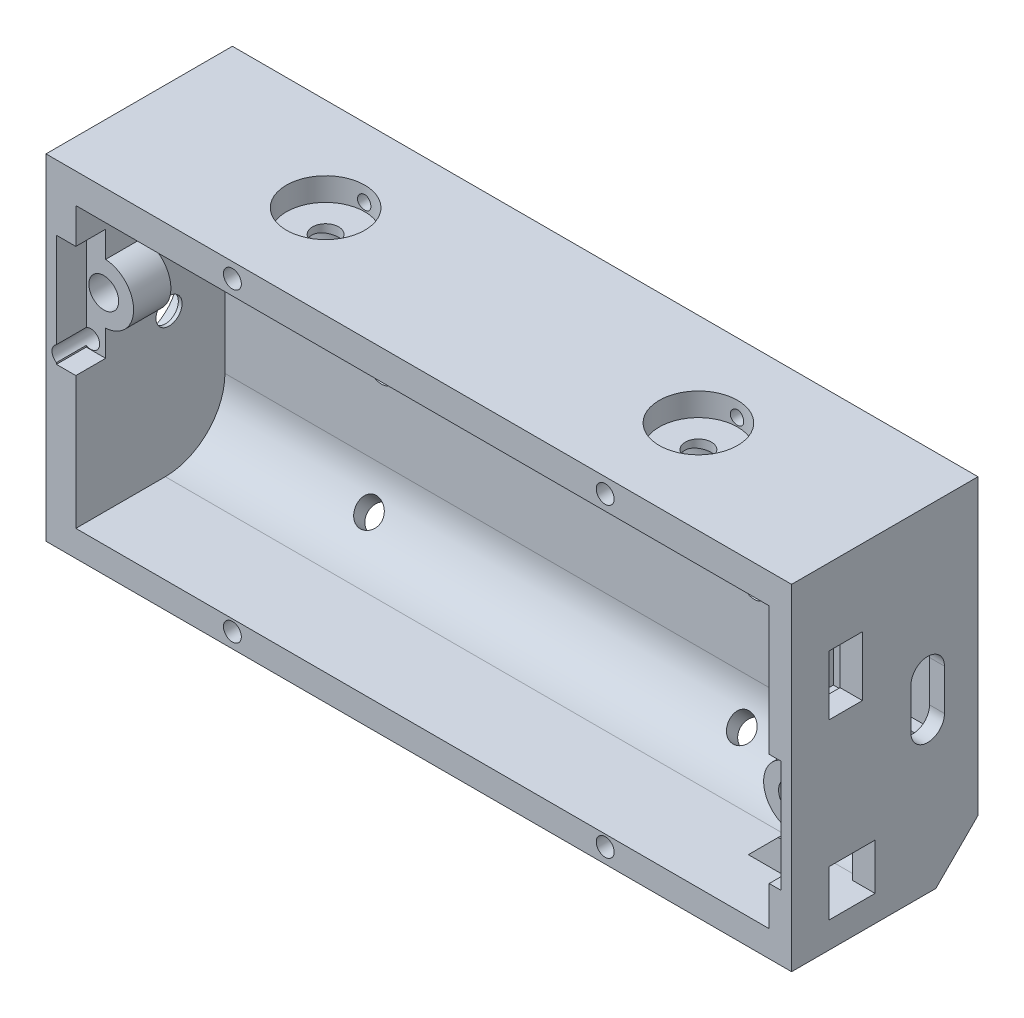
from build123d import *
from build123d.topology import SkipClean

# Parameters (mm, degrees)
ESBO_O1_W                   = 100
ESBO_O1_H                   = 45
ESBO_O1_W_2                 = 93
ESBO_O1_H_2                 = 37.5
RESSALTO_EXTRUS_O1_DEPTH    = 25
ESBO_O1_3_W                 = 93
ESBO_O1_3_H                 = 37.5
RESSALTO_EXTRUS_O2_DEPTH    = 5
ESBO_O2_R                   = 5.25
ESBO_O2_R_2                 = 1.75
CORTE_EXTRUS_O1_DEPTH       = 3.1
ESBO_O14_R                  = 5.25
ESBO_O14_R_2                = 1.75
CORTE_EXTRUS_O17_DEPTH      = 3.5
ESBO_O4_R                   = 5.15
ESBO_O4_R_2                 = 1.75
CORTE_EXTRUS_O2_DEPTH       = 3.5
CORTE_EXTRUS_O3_DEPTH       = 106.50473923
FILETE1_R                   = 8
ESBO_O6_W                   = 12.5
ESBO_O6_H                   = 6.5
ESBO_O6_R                   = 1.75
CORTE_EXTRUS_O4_DEPTH       = 3.2
ESBO_O4_2_R                 = 1.75
CORTE_EXTRUS_O5_DEPTH       = 61.259853966
CORTE_EXTRUS_O6_REACH       = 73.764
ESBO_O2_2_R                 = 1.75
ESBO_O6_2_R                 = 1.75
CORTE_EXTRUS_O8_DEPTH       = 78.347822255
DIY_CHARGER_START           = -20
ESBO_O8_W                   = 16
ESBO_O8_H                   = 16
DIY_CHARGER_DEPTH           = 6
DIY_CHARGER_DEPTH_BACK      = 1.5
CORTE_EXTRUS_O11_DEPTH      = 104.611051534
ESBO_O10_R                  = 1
CORTE_EXTRUS_O12_DEPTH      = 2
CORTE_EXTRUS_O12_DEPTH_BACK = 1.6
ESBO_O12_W                  = 6.2
ESBO_O12_H                  = 6.2
ESBO_O12_W_2                = 4.5
ESBO_O12_H_2                = 8
CORTE_EXTRUS_O14_DEPTH      = 103.665719693
ESBO_O12_3_R                = 1
CORTE_EXTRUS_O15_DEPTH      = 3
CORTE_EXTRUS_O15_DEPTH_BACK = 1.5
RESSALTO_EXTRUS_O4_START    = -4
RESSALTO_EXTRUS_O4_DEPTH    = 5
ESBO_O13_3_R                = 2
CORTE_EXTRUS_O16_DEPTH      = 10
CORTE_EXTRUS_O18_REACH      = 107.505
ESBO_O14_2_R                = 1.75
ESBO_O16_W                  = 4.7
ESBO_O16_H                  = 15
CORTE_EXTRUS_O19_DEPTH      = 4
ESBO_O17_R                  = 1.2
CORTE_EXTRUS_O20_DEPTH      = 6
ESBO_O18_R                  = 0.9
CORTE_EXTRUS_O21_DEPTH      = 19.873476
ESBO_O19_R                  = 1.2
ESBO_O19_R_2                = 0.9
CORTE_EXTRUS_O23_DEPTH      = 12
CORTE_EXTRUS_O24_REACH      = 73.764
ESBO_O19_2_R                = 0.9
RESSALTO_EXTRUS_O5_START    = 2
RESSALTO_EXTRUS_O5_DEPTH    = 2


with BuildPart() as part:
    # Esbo_o1 → Ressalto-extrus_o1 (new body)
    with BuildSketch(Plane.XY):
        Rectangle(ESBO_O1_W, ESBO_O1_H)
        with Locations((0.5, -0.25)):
            Rectangle(ESBO_O1_W_2, ESBO_O1_H_2, mode=Mode.SUBTRACT)
    extrude(amount=RESSALTO_EXTRUS_O1_DEPTH)

    # Esbo_o1_3 → Ressalto-extrus_o2 (add)
    with BuildSketch(Plane.XY):
        with Locations((0.5, -0.25)):
            Rectangle(ESBO_O1_3_W, ESBO_O1_3_H)
    extrude(amount=RESSALTO_EXTRUS_O2_DEPTH)

    # Esbo_o2 → Corte-extrus_o1 (cut)
    with BuildSketch(Plane.XZ.offset(-22.5)):
        with Locations(Location((-25, 12.5, 0), (0, 0, 90))):
            Circle(ESBO_O2_R)
        with Locations(Location((-25, 12.5, 0), (0, 0, 90))):
            Circle(ESBO_O2_R_2, mode=Mode.SUBTRACT)
        with Locations(Location((25, 12.5, 0), (0, 0, 90))):
            Circle(ESBO_O2_R)
        with Locations(Location((25, 12.5, 0), (0, 0, 90))):
            Circle(ESBO_O2_R_2, mode=Mode.SUBTRACT)
    extrude(amount=CORTE_EXTRUS_O1_DEPTH, mode=Mode.SUBTRACT)

    # Esbo_o14 → Corte-extrus_o17 (cut)
    with BuildSketch(Plane.ZY.offset(50)):
        with Locations(Location((12.5, 0, 0), (0, 0, 270))):
            Circle(ESBO_O14_R)
        with Locations(Location((12.5, 0, 0), (0, 0, 270))):
            Circle(ESBO_O14_R_2, mode=Mode.SUBTRACT)
    extrude(amount=-CORTE_EXTRUS_O17_DEPTH, mode=Mode.SUBTRACT)

    # Esbo_o4 → Corte-extrus_o2 (cut)
    with BuildSketch(Plane(origin=(0, 0, 0), x_dir=(-1, 0, 0), z_dir=(0, 0, -1))):
        with Locations((-25, 0)):
            Circle(ESBO_O4_R)
        with Locations((-25, 0)):
            Circle(ESBO_O4_R_2, mode=Mode.SUBTRACT)
        with Locations((25, 0)):
            Circle(ESBO_O4_R)
        with Locations((25, 0)):
            Circle(ESBO_O4_R_2, mode=Mode.SUBTRACT)
    extrude(amount=-CORTE_EXTRUS_O2_DEPTH, mode=Mode.SUBTRACT)

    # Esbo_o5 → Corte-extrus_o3 (cut, through all)
    with BuildSketch(Plane.ZY.offset(50)):
        Polygon((0, -16.843145751), (5.656854249, -22.5), (0, -22.5), align=None)
    extrude(amount=-CORTE_EXTRUS_O3_DEPTH, mode=Mode.SUBTRACT)

    # Filete1
    filete1_edges = [part.edges().sort_by_distance(p)[0] for p in [
        (0.5, 18.5, 5),
        (0.5, -19, 5),
    ]]
    fillet(filete1_edges, radius=FILETE1_R)

    # Esbo_o6 → Corte-extrus_o4 (cut)
    with BuildSketch(Plane(origin=(0, 8.421572875, -25.264718626), x_dir=(1, 0, 0), z_dir=(0, 0.7071067811865477, 0.7071067811865475))):
        with Locations((25, -39.72970773)):
            Rectangle(ESBO_O6_W, ESBO_O6_H)
        with Locations(Location((25, -39.72970773, 0), (0, 0, 90))):
            Circle(ESBO_O6_R, mode=Mode.SUBTRACT)
        with Locations((-25, -39.72970773)):
            Rectangle(ESBO_O6_W, ESBO_O6_H)
        with Locations(Location((-25, -39.72970773, 0), (0, 0, 90))):
            Circle(ESBO_O6_R, mode=Mode.SUBTRACT)
    extrude(amount=CORTE_EXTRUS_O4_DEPTH, mode=Mode.SUBTRACT)

    # Esbo_o4_2 → Corte-extrus_o5 (cut, through all)
    with BuildSketch(Plane(origin=(0, 0, 0), x_dir=(-1, 0, 0), z_dir=(0, 0, -1))):
        with Locations((-25, 0)):
            Circle(ESBO_O4_2_R)
        with Locations((25, 0)):
            Circle(ESBO_O4_2_R)
    extrude(amount=-CORTE_EXTRUS_O5_DEPTH, mode=Mode.SUBTRACT)

    # Esbo_o2_2 → Corte-extrus_o6 (cut, up to next)
    with BuildSketch(Plane.XZ.offset(-22.5), mode=Mode.PRIVATE) as corte_extrus_o6_sk1:
        with Locations(Location((-25, 12.5, 0), (0, 0, 163.398450401))):
            Circle(ESBO_O2_2_R)
    corte_extrus_o6_tool1 = extrude(corte_extrus_o6_sk1.sketch, amount=CORTE_EXTRUS_O6_REACH, mode=Mode.PRIVATE) & part.part
    # Esbo_o2_2 → Corte-extrus_o6 (cut, up to next)
    with BuildSketch(Plane.XZ.offset(-22.5), mode=Mode.PRIVATE) as corte_extrus_o6_sk2:
        with Locations(Location((25, 12.5, 0), (0, 0, 16.601549599))):
            Circle(ESBO_O2_2_R)
    corte_extrus_o6_tool2 = extrude(corte_extrus_o6_sk2.sketch, amount=CORTE_EXTRUS_O6_REACH, mode=Mode.PRIVATE) & part.part
    add(corte_extrus_o6_tool1.solids().sort_by_distance((-25, 22.5, 12.5))[0], mode=Mode.SUBTRACT)
    add(corte_extrus_o6_tool2.solids().sort_by_distance((25, 22.5, 12.5))[0], mode=Mode.SUBTRACT)

    # Esbo_o6_2 → Corte-extrus_o8 (cut, through all)
    with BuildSketch(Plane(origin=(0, 8.421572875, -25.264718626), x_dir=(1, 0, 0), z_dir=(0, 0.7071067811865477, 0.7071067811865475))):
        with Locations(Location((25, -39.72970773, 0), (0, 0, 90))):
            Circle(ESBO_O6_2_R)
        with Locations(Location((-25, -39.72970773, 0), (0, 0, 90))):
            Circle(ESBO_O6_2_R)
    extrude(amount=CORTE_EXTRUS_O8_DEPTH, mode=Mode.SUBTRACT)

    # Esbo_o8 → DIY-charger (cut, two sides)
    with BuildSketch(Plane.XY.offset(25).offset(DIY_CHARGER_START)) as diy_charger_sk:
        with Locations((40, -2)):
            Rectangle(ESBO_O8_W, ESBO_O8_H)
    extrude(amount=DIY_CHARGER_DEPTH, mode=Mode.SUBTRACT)
    extrude(diy_charger_sk.sketch, amount=-DIY_CHARGER_DEPTH_BACK, mode=Mode.SUBTRACT)

    # Esbo_o9 → Corte-extrus_o11 (cut, through all)
    with BuildSketch(Plane.ZY.offset(-48)):
        with BuildLine():
            Line((9, 2.75), (9, -2.75))
            ThreePointArc((9, -2.75), (6.75, -5), (4.5, -2.75))
            Line((4.5, -2.75), (4.5, 2.75))
            ThreePointArc((4.5, 2.75), (6.75, 5), (9, 2.75))
        make_face()
    extrude(amount=-CORTE_EXTRUS_O11_DEPTH, mode=Mode.SUBTRACT)

    # Esbo_o10 → Corte-extrus_o12 (cut, two sides)
    with BuildSketch(Plane.XY.offset(3.5)) as corte_extrus_o12_sk:
        with Locations((30.9, 3)):
            Circle(ESBO_O10_R)
        Polygon((47.5, -8), (47.5, 4), (40.5, 4), (40.5, 5.5), (32.5, 5.5), (32.5, -9.5), (40.5, -9.5), (40.5, -8), align=None)
    extrude(amount=CORTE_EXTRUS_O12_DEPTH, mode=Mode.SUBTRACT)
    extrude(corte_extrus_o12_sk.sketch, amount=-CORTE_EXTRUS_O12_DEPTH_BACK, mode=Mode.SUBTRACT)

    # Esbo_o12 → Corte-extrus_o14 (cut, through all)
    with BuildSketch(Plane.ZY.offset(-47)):
        with Locations((16.9, -15.9)):
            Rectangle(ESBO_O12_W, ESBO_O12_H)
        with Locations((17.75, 8.25)):
            Rectangle(ESBO_O12_W_2, ESBO_O12_H_2)
    extrude(amount=-CORTE_EXTRUS_O14_DEPTH, mode=Mode.SUBTRACT)

    # Esbo_o12_3 → Corte-extrus_o15 (cut, two sides)
    with BuildSketch(Plane.ZY.offset(-47)) as corte_extrus_o15_sk:
        with Locations(Location((17.75, 0, 0), (0, 0, 90))):
            Circle(ESBO_O12_3_R)
        with Locations(Location((17.75, 16.5, 0), (0, 0, 90))):
            Circle(ESBO_O12_3_R)
    extrude(amount=CORTE_EXTRUS_O15_DEPTH, mode=Mode.SUBTRACT)
    extrude(corte_extrus_o15_sk.sketch, amount=-CORTE_EXTRUS_O15_DEPTH_BACK, mode=Mode.SUBTRACT)

    # Esbo_o13 → Ressalto-extrus_o4 (add)
    with BuildSketch(Plane.XY.offset(25).offset(RESSALTO_EXTRUS_O4_START)):
        with BuildLine():
            ThreePointArc((-46, 2.257820144), (-43.334524053, 3.511387212), (-42.25, 6.25))
            ThreePointArc((-42.25, 6.25), (-43.334524053, 8.988612788), (-46, 10.242179856))
            Line((-46, 10.242179856), (-46, 8.234313483))
            ThreePointArc((-46, 8.234313483), (-44.75, 7.572875656), (-44.25, 6.25))
            ThreePointArc((-44.25, 6.25), (-44.75, 4.927124344), (-46, 4.265686517))
            Line((-46, 4.265686517), (-46, 2.257820144))
        make_face()
        with BuildLine():
            ThreePointArc((47, -8.104049622), (44.25, -6.25), (47, -4.395950378))
            Line((47, -4.395950378), (47, -2.320941589))
            ThreePointArc((47, -2.320941589), (42.25, -6.25), (47, -10.179058411))
            Line((47, -10.179058411), (47, -8.104049622))
        make_face()
    extrude(amount=-RESSALTO_EXTRUS_O4_DEPTH)

    # Esbo_o13_3 → Corte-extrus_o16 (cut)
    with SkipClean():  # the faces are left unmerged after this step: merging them gives an invalid solid
        with BuildSketch(Plane.XY.offset(25)):
            with Locations(Location((46.25, -6.25, 0), (0, 0, 67.975687163))):
                Circle(ESBO_O13_3_R)
            with Locations(Location((-46.25, 6.25, 0), (0, 0, 277.180755781))):
                Circle(ESBO_O13_3_R)
        extrude(amount=-CORTE_EXTRUS_O16_DEPTH, mode=Mode.SUBTRACT)

    # Esbo_o14_2 → Corte-extrus_o18 (cut, up to next)
    with BuildSketch(Plane.ZY.offset(50), mode=Mode.PRIVATE) as corte_extrus_o18_sk1:
        with Locations(Location((12.5, 0, 0), (0, 0, 270))):
            Circle(ESBO_O14_2_R)
    corte_extrus_o18_tool1 = extrude(corte_extrus_o18_sk1.sketch, amount=-CORTE_EXTRUS_O18_REACH, mode=Mode.PRIVATE) & part.part
    add(corte_extrus_o18_tool1.solids().sort_by_distance((-50, 0, 12.5))[0], mode=Mode.SUBTRACT)

    # Esbo_o16 → Corte-extrus_o19 (cut)
    with SkipClean():  # the faces are left unmerged after this step: merging them gives an invalid solid
        with BuildSketch(Plane.XY.offset(25)):
            with Locations((-46.25, 6.25)):
                Rectangle(ESBO_O16_W, ESBO_O16_H)
            with Locations((46.25, -6.25)):
                Rectangle(ESBO_O16_W, ESBO_O16_H)
        extrude(amount=-CORTE_EXTRUS_O19_DEPTH, mode=Mode.SUBTRACT)

    # Esbo_o17 → Corte-extrus_o20 (cut)
    with SkipClean():  # the faces are left unmerged after this step: merging them gives an invalid solid
        with BuildSketch(Plane.XY.offset(25)):
            with Locations((-25, 20.5)):
                Circle(ESBO_O17_R)
            with Locations((25, 20.5)):
                Circle(ESBO_O17_R)
            with Locations((-48, 0)):
                Circle(ESBO_O17_R)
            with Locations((-25, -20.5)):
                Circle(ESBO_O17_R)
            with Locations(Location((25, -20.5, 0), (0, 0, 180))):
                Circle(ESBO_O17_R)
        extrude(amount=-CORTE_EXTRUS_O20_DEPTH, mode=Mode.SUBTRACT)

    # Esbo_o18 → Corte-extrus_o21 (cut)
    with SkipClean():  # the faces are left unmerged after this step: merging them gives an invalid solid
        with BuildSketch(Plane.XY.offset(25)):
            with Locations((-25, 20.5)):
                Circle(ESBO_O18_R)
            with Locations((25, 20.5)):
                Circle(ESBO_O18_R)
            with Locations((-25, -20.5)):
                Circle(ESBO_O18_R)
            with Locations(Location((25, -20.5, 0), (0, 0, 61.786353056))):
                Circle(ESBO_O18_R)
            with Locations((-48, 0)):
                Circle(ESBO_O18_R)
        extrude(amount=-CORTE_EXTRUS_O21_DEPTH, mode=Mode.SUBTRACT)

    # Esbo_o19 → Corte-extrus_o23 (cut)
    with SkipClean():  # the faces are left unmerged after this step: merging them gives an invalid solid
        with BuildSketch(Plane.XZ.offset(22.5)):
            with Locations(Location((-25, 2, 0), (0, 0, 270))):
                Circle(ESBO_O19_R)
            with Locations(Location((-25, 2, 0), (0, 0, 270))):
                Circle(ESBO_O19_R_2, mode=Mode.SUBTRACT)
            with Locations(Location((25, 2, 0), (0, 0, 138.631974532))):
                Circle(ESBO_O19_R)
            with Locations(Location((25, 2, 0), (0, 0, 270))):
                Circle(ESBO_O19_R_2, mode=Mode.SUBTRACT)
        extrude(amount=-CORTE_EXTRUS_O23_DEPTH, mode=Mode.SUBTRACT)

    # Esbo_o19_2 → Corte-extrus_o24 (cut, up to next)
    with BuildSketch(Plane.XZ.offset(22.5), mode=Mode.PRIVATE) as corte_extrus_o24_sk1:
        with Locations(Location((-25, 2, 0), (0, 0, 270))):
            Circle(ESBO_O19_2_R)
    corte_extrus_o24_tool1 = extrude(corte_extrus_o24_sk1.sketch, amount=-CORTE_EXTRUS_O24_REACH, mode=Mode.PRIVATE) & part.part
    # Esbo_o19_2 → Corte-extrus_o24 (cut, up to next)
    with BuildSketch(Plane.XZ.offset(22.5), mode=Mode.PRIVATE) as corte_extrus_o24_sk2:
        with Locations(Location((25, 2, 0), (0, 0, 270))):
            Circle(ESBO_O19_2_R)
    corte_extrus_o24_tool2 = extrude(corte_extrus_o24_sk2.sketch, amount=-CORTE_EXTRUS_O24_REACH, mode=Mode.PRIVATE) & part.part
    add(corte_extrus_o24_tool1.solids().sort_by_distance((-25, -22.5, 2))[0], mode=Mode.SUBTRACT)
    add(corte_extrus_o24_tool2.solids().sort_by_distance((25, -22.5, 2))[0], mode=Mode.SUBTRACT)

    # Esbo_o20 → Ressalto-extrus_o5 (add)
    with SkipClean():  # the faces are left unmerged after this step: merging them gives an invalid solid
        with BuildSketch(Plane.XY.offset(13.8).offset(RESSALTO_EXTRUS_O5_START)):
            Polygon((45, -19), (45, -15), (41, -15), (37, -19), align=None)
        extrude(amount=RESSALTO_EXTRUS_O5_DEPTH)


solid = part.part
